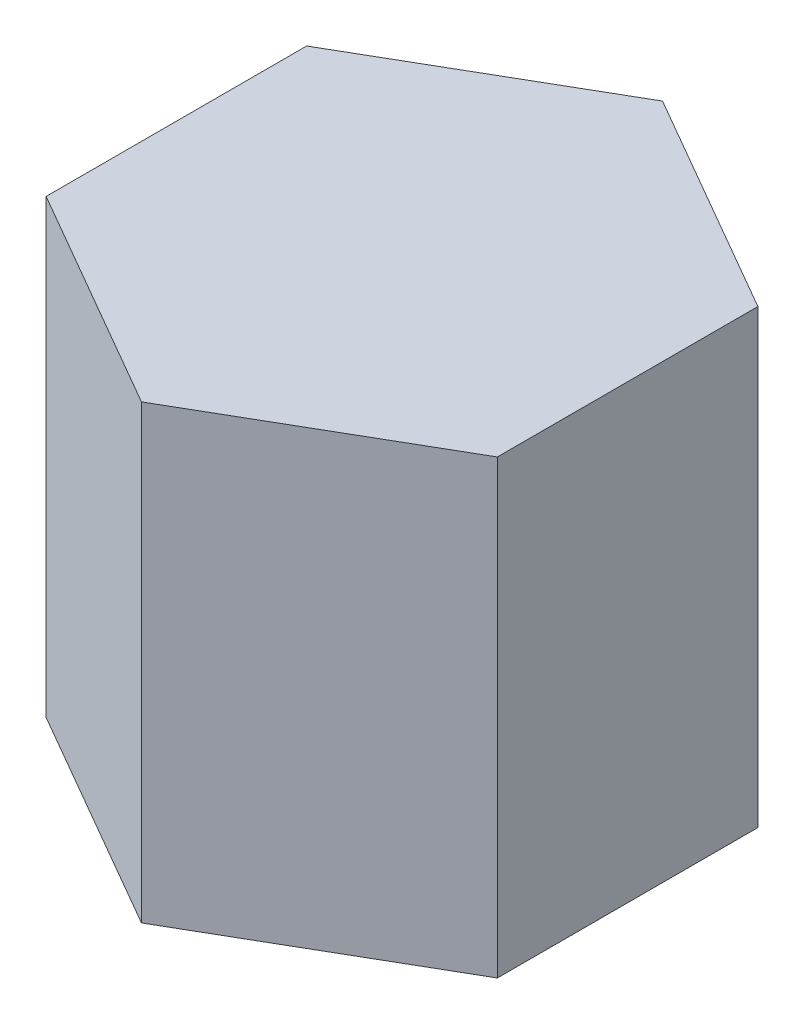
from build123d import *

# Parameters (mm, degrees)
BOSS_EXTRUDE1_DEPTH = 100


with BuildPart() as part:
    # Sketch1 → Boss-Extrude1 (new body)
    with BuildSketch(Plane(origin=(0, 0, 0), x_dir=(1, 0, 0), z_dir=(0, 1, 0))):
        Polygon((-50, -28.867513459), (0, -57.735026919), (50, -28.867513459), (50, 28.867513459), (0, 57.735026919), (-50, 28.867513459), align=None)
    extrude(amount=BOSS_EXTRUDE1_DEPTH)


solid = part.part
